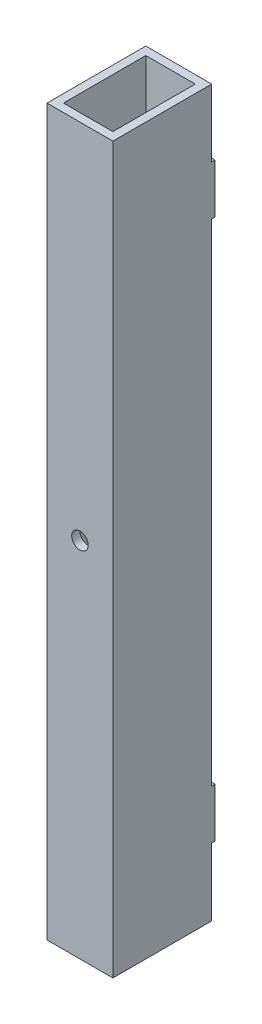
from build123d import *

# Parameters (mm, degrees)
SKETCH1_W           = 50.8
SKETCH1_H           = 76.2
SKETCH1_W_2         = 38.1
SKETCH1_H_2         = 63.5
BOSS_EXTRUDE1_DEPTH = 279.4
SKETCH2_R           = 6.35
CUT_EXTRUDE1_DEPTH  = 77.2
SKETCH3_W           = 50.8
SKETCH3_H           = 38.1
BOSS_EXTRUDE2_DEPTH = 2.54


with BuildPart() as part:
    # Sketch1 → Boss-Extrude1 (new body, symmetric)
    with BuildSketch(Plane(origin=(0, 0, 0), x_dir=(1, 0, 0), z_dir=(0, 1, 0))):
        Rectangle(SKETCH1_W, SKETCH1_H)
        Rectangle(SKETCH1_W_2, SKETCH1_H_2, mode=Mode.SUBTRACT)
    extrude(amount=BOSS_EXTRUDE1_DEPTH, both=True)

    # Sketch2 → Cut-Extrude1 (cut, through all)
    with BuildSketch(Plane.XY.offset(38.1)):
        Circle(SKETCH2_R)
    extrude(amount=-CUT_EXTRUDE1_DEPTH, mode=Mode.SUBTRACT)

    # Sketch3 → Boss-Extrude2 (add)
    with BuildSketch(Plane(origin=(0, 0, -38.1), x_dir=(-1, 0, 0), z_dir=(0, 0, -1))):
        with Locations((0, -208.386065816)):
            Rectangle(SKETCH3_W, SKETCH3_H)
    boss_extrude2 = extrude(amount=BOSS_EXTRUDE2_DEPTH)

    # Mirror1: Boss-Extrude2 across plane
    add(boss_extrude2.mirror(Plane.ZX))


solid = part.part
